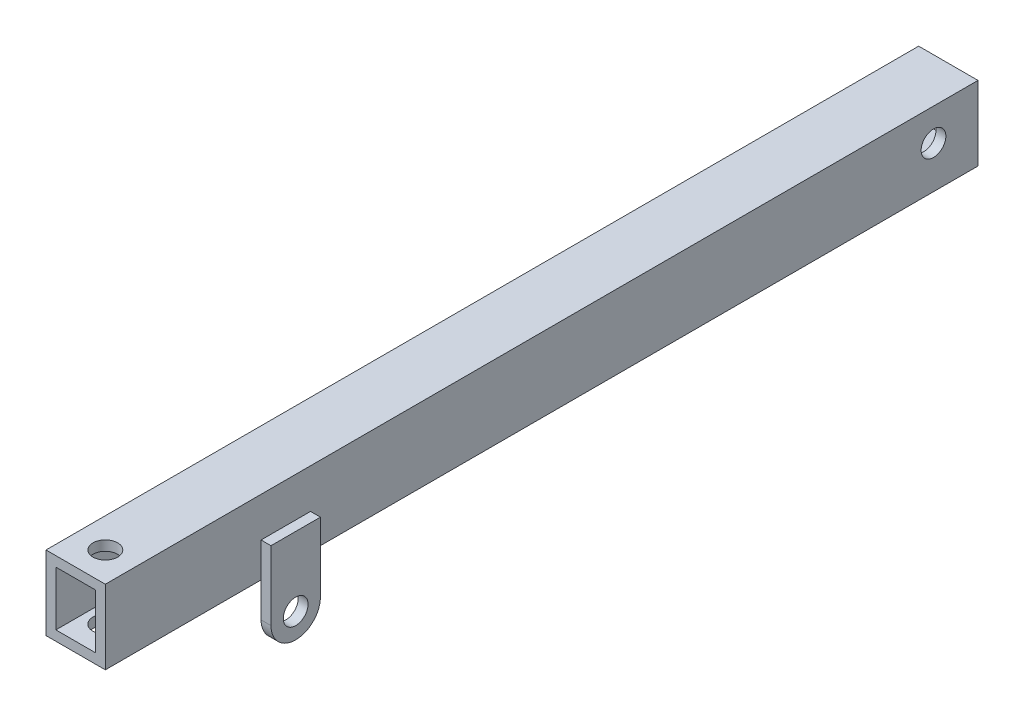
from build123d import *

# Parameters (mm, degrees)
CROQUIS1_W                = 12
CROQUIS1_H                = 15
CROQUIS1_W_2              = 8
CROQUIS1_H_2              = 11
SALIENTE_EXTRUIR1_DEPTH   = 176.5
CROQUIS3_R                = 2.5
SALIENTE_EXTRUIR2_DEPTH   = 2
SIMETR_A2_COPY_1_SKETCH_R = 2.5
SIMETR_A2_COPY_1_DEPTH    = 2
SKETCH1_R                 = 2.5
CUT_EXTRUDE1_DEPTH        = 28
SKETCH6_W                 = 176.5
SKETCH6_H                 = 30.622513857
CUT_EXTRUDE2_DEPTH        = 15
SKETCH7_W                 = 10
SKETCH7_H                 = 20.073339824
CUT_EXTRUDE3_DEPTH        = 10
SKETCH8_R                 = 2.5
CUT_EXTRUDE4_DEPTH        = 15


with BuildPart() as part:
    # Croquis1 → Saliente-Extruir1 (new body, symmetric)
    with BuildSketch(Plane.XY):
        Rectangle(CROQUIS1_W, CROQUIS1_H)
        Rectangle(CROQUIS1_W_2, CROQUIS1_H_2, mode=Mode.SUBTRACT)
    extrude(amount=SALIENTE_EXTRUIR1_DEPTH, both=True)

    # Croquis3 → Saliente-Extruir2 (add)
    with BuildSketch(Plane.ZY.offset(6)):
        with BuildLine():
            Line((-145, -14.5), (-145, -0.5))
            Line((-145, -0.5), (-135, -0.5))
            Line((-135, -0.5), (-135, -14.5))
            ThreePointArc((-135, -14.5), (-140, -19.5), (-145, -14.5))
        make_face()
        with Locations((-140, -14.5)):
            Circle(CROQUIS3_R, mode=Mode.SUBTRACT)
    saliente_extruir2 = extrude(amount=SALIENTE_EXTRUIR2_DEPTH)

    # Simetría1: Saliente-Extruir2 across plane
    add(saliente_extruir2.mirror(Plane(origin=(0, 0, 0), x_dir=(0, 0, 1), z_dir=(1, 0, 0))))

    # Simetría2: Saliente-Extruir2 across plane
    add(saliente_extruir2.mirror(Plane.XY))

    # Simetría2 copy 1 sketch → Simetría2 copy 1 (add)
    with BuildSketch(Plane(origin=(6, 0, 0), x_dir=(0, 0, -1), z_dir=(1, 0, 0))):
        with BuildLine():
            Line((-145, -14.5), (-145, -0.5))
            Line((-145, -0.5), (-135, -0.5))
            Line((-135, -0.5), (-135, -14.5))
            ThreePointArc((-135, -14.5), (-140, -19.5), (-145, -14.5))
        make_face()
        with Locations((-140, -14.5)):
            Circle(SIMETR_A2_COPY_1_SKETCH_R, mode=Mode.SUBTRACT)
    extrude(amount=SIMETR_A2_COPY_1_DEPTH)

    # Sketch1 → Cut-Extrude1 (cut, through all)
    with BuildSketch(Plane(origin=(0, 7.5, 0), x_dir=(1, 0, 0), z_dir=(0, 1, 0))):
        with Locations((0, 170.5)):
            Circle(SKETCH1_R)
        with Locations((0, -170.5)):
            Circle(SKETCH1_R)
    extrude(amount=-CUT_EXTRUDE1_DEPTH, mode=Mode.SUBTRACT)

    # Sketch6 → Cut-Extrude2 (cut, through all)
    with BuildSketch(Plane.ZY.offset(6)):
        with Locations((-88.25, -7.811256929)):
            Rectangle(SKETCH6_W, SKETCH6_H)
    extrude(amount=-CUT_EXTRUDE2_DEPTH, mode=Mode.SUBTRACT)

    # Sketch7 → Cut-Extrude3 (cut)
    with BuildSketch(Plane.ZY.offset(8)):
        with Locations((-140, -10.536669912)):
            Rectangle(SKETCH7_W, SKETCH7_H)
    extrude(amount=-CUT_EXTRUDE3_DEPTH, mode=Mode.SUBTRACT)

    # Sketch8 → Cut-Extrude4 (cut, through all)
    with BuildSketch(Plane(origin=(6, 0, 0), x_dir=(0, 0, -1), z_dir=(1, 0, 0))):
        with Locations((-9, 1)):
            Circle(SKETCH8_R)
    extrude(amount=-CUT_EXTRUDE4_DEPTH, mode=Mode.SUBTRACT)


solid = part.part
